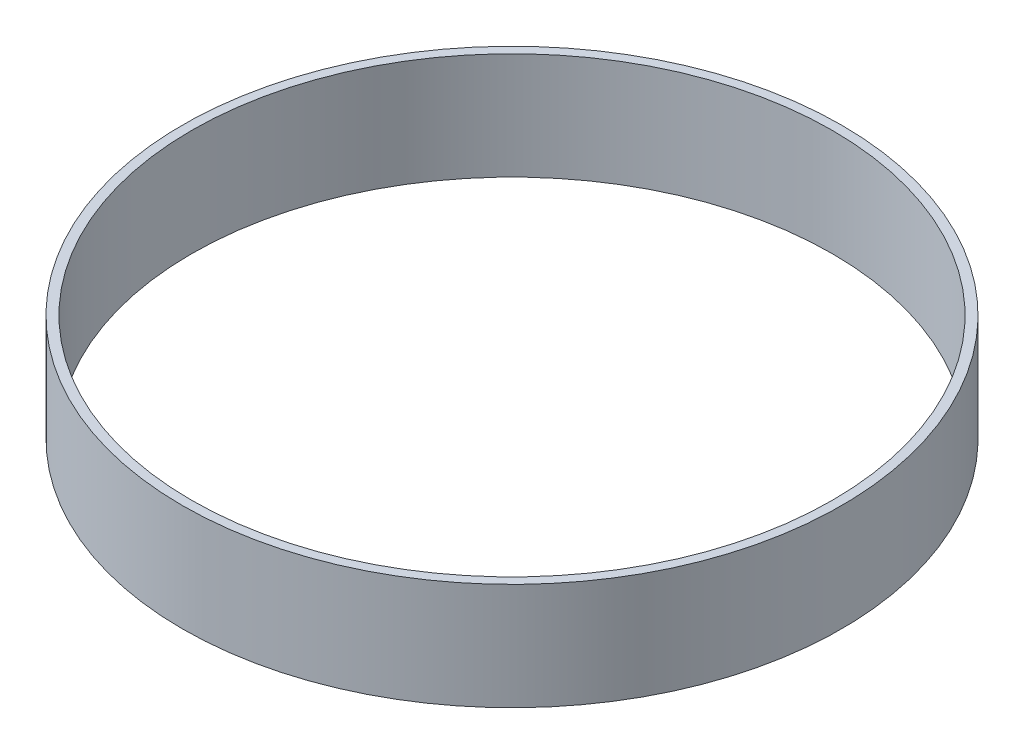
from build123d import *

# Parameters (mm, degrees)
SKETCH1_R           = 78.359
SKETCH1_R_2         = 76.1746
BOSS_EXTRUDE1_DEPTH = 25.4


with BuildPart() as part:
    # Sketch1 → Boss-Extrude1 (new body)
    with BuildSketch(Plane(origin=(0, 0, 0), x_dir=(1, 0, 0), z_dir=(0, 1, 0))):
        Circle(SKETCH1_R)
        Circle(SKETCH1_R_2, mode=Mode.SUBTRACT)
    extrude(amount=BOSS_EXTRUDE1_DEPTH)


solid = part.part
